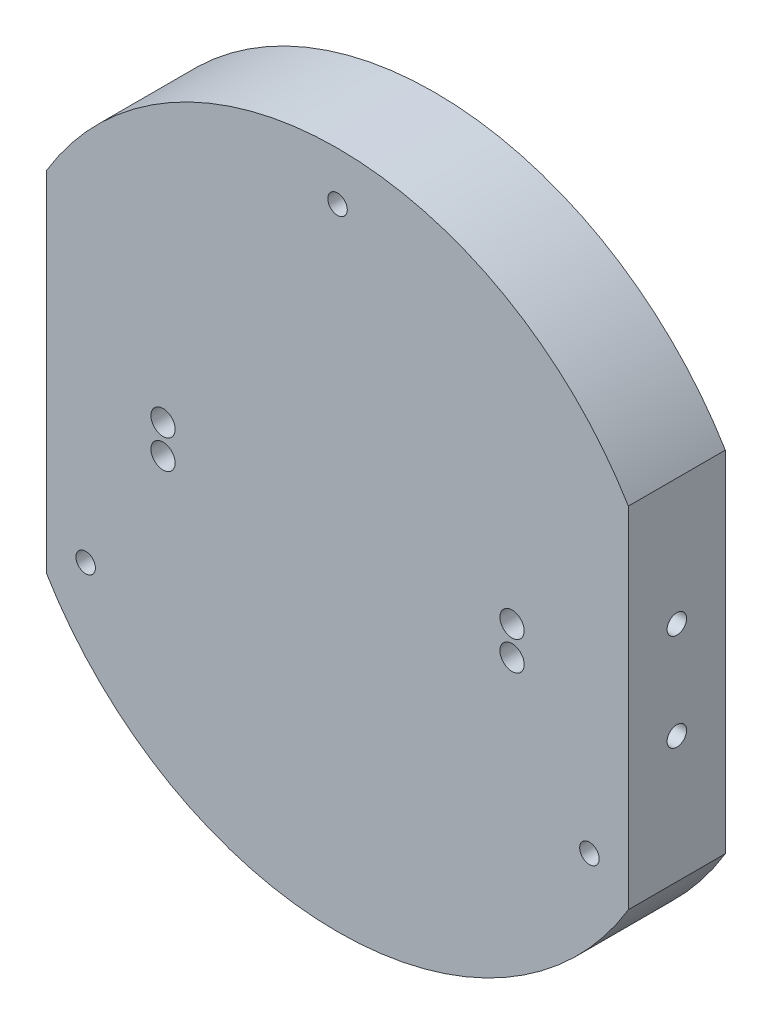
from build123d import *

# Parameters (mm, degrees)
SKETCH1_W                   = 177.8
SKETCH1_H                   = 177.8
EXTRUDE1_DEPTH              = 12.7
F_10_CLEARANCE_HOLE1_D      = 5.1054
CIRPATTERN1_COUNT           = 3
SKETCH5_W                   = 177.8
SKETCH5_H                   = 31.75
EXTRUDE2_DEPTH              = 1.5875
SKETCH8_R                   = 152.4
SKETCH8_R_2                 = 88.9
EXTRUDE3_DEPTH              = 13.7
SKETCH9_W                   = 254
SKETCH9_H                   = 254
SKETCH9_W_2                 = 152.4
SKETCH9_H_2                 = 177.8
EXTRUDE4_DEPTH              = 13.7
SKETCH10_W                  = 152.4
SKETCH10_H                  = 38.1
EXTRUDE5_DEPTH              = 12.7
EXTRUDE5_DEPTH_BACK         = 2.54
F_1_4_0_25_DIAMETER_HOLE1_D = 6.35
LPATTERN1_COUNT             = 2
LPATTERN1_PITCH             = 7.62
LPATTERN1_COUNT_DIR2        = 2
LPATTERN1_PITCH_DIR2        = 91.44
F_1_4_20_TAPPED_HOLE1_D     = 5.1054
F_1_4_20_TAPPED_HOLE1_DEPTH = 19.05
F_1_4_20_TAPPED_HOLE1_TIP   = 1.533817
F_1_4_20_TAPPED_HOLE2_D     = 5.1054
F_1_4_20_TAPPED_HOLE2_DEPTH = 19.05
F_1_4_20_TAPPED_HOLE2_TIP   = 1.533817
SKETCH17_R                  = 2.5527
EXTRUDE6_DEPTH              = 12.7


with BuildPart() as part:
    # Sketch1 → Extrude1 (new body)
    with BuildSketch(Plane.XY):
        Rectangle(SKETCH1_W, SKETCH1_H)
    extrude(amount=EXTRUDE1_DEPTH)

    # 10 Clearance Hole1 (through all)
    with Locations(Plane(origin=(0, 0, 0), x_dir=(-1, 0, 0), z_dir=(0, 0, -1))):
        with Locations((0, 76.2)):
            f_10_clearance_hole1 = Hole(F_10_CLEARANCE_HOLE1_D / 2)

    # CirPattern1: 10 Clearance Hole1 ×3 about axis
    cirpattern1_axis = Axis((0, 0, 0), (0, 0, 1))
    for i in range(1, CIRPATTERN1_COUNT):
        add(f_10_clearance_hole1.rotate(cirpattern1_axis, i * 360 / CIRPATTERN1_COUNT), mode=Mode.SUBTRACT)

    # Sketch5 → Extrude2 (cut)
    with BuildSketch(Plane.XY):
        Rectangle(SKETCH5_W, SKETCH5_H)
    extrude(amount=EXTRUDE2_DEPTH, mode=Mode.SUBTRACT)

    # Sketch8 → Extrude3 (cut, through all)
    with BuildSketch(Plane.XY.offset(12.7)):
        Circle(SKETCH8_R)
        Circle(SKETCH8_R_2, mode=Mode.SUBTRACT)
    extrude(amount=-EXTRUDE3_DEPTH, mode=Mode.SUBTRACT)

    # Sketch9 → Extrude4 (cut, through all)
    with BuildSketch(Plane.XY.offset(12.7)):
        Rectangle(SKETCH9_W, SKETCH9_H)
        Rectangle(SKETCH9_W_2, SKETCH9_H_2, mode=Mode.SUBTRACT)
    extrude(amount=-EXTRUDE4_DEPTH, mode=Mode.SUBTRACT)

    # Sketch10 → Extrude5 (add, two sides)
    with BuildSketch(Plane(origin=(0, 0, 0), x_dir=(-1, 0, 0), z_dir=(0, 0, -1))) as extrude5_sk:
        Rectangle(SKETCH10_W, SKETCH10_H)
    extrude(amount=EXTRUDE5_DEPTH)
    extrude(extrude5_sk.sketch, amount=-EXTRUDE5_DEPTH_BACK)

    # 1_4 _0.25_ Diameter Hole1 (through all)
    with Locations(Plane.XY.offset(12.7)):
        with Locations((-45.72, 3.81)):
            f_1_4_0_25_diameter_hole1 = Hole(F_1_4_0_25_DIAMETER_HOLE1_D / 2)

    # LPattern1: 1_4 _0.25_ Diameter Hole1 2 × 2
    with Locations(*[(j * LPATTERN1_PITCH_DIR2, -i * LPATTERN1_PITCH, 0) for i in range(LPATTERN1_COUNT) for j in range(LPATTERN1_COUNT_DIR2) if (i, j) != (0, 0)]):
        add(f_1_4_0_25_diameter_hole1, mode=Mode.SUBTRACT)

    # 1_4-20 Tapped Hole1
    with Locations(Plane.ZY.offset(76.2)):
        with Locations((0, 12.7), (0, -12.7)):
            Hole(F_1_4_20_TAPPED_HOLE1_D / 2, depth=F_1_4_20_TAPPED_HOLE1_DEPTH)
            with Locations((0, 0, -(F_1_4_20_TAPPED_HOLE1_DEPTH + F_1_4_20_TAPPED_HOLE1_TIP / 2))):  # 118° drill point
                Cone(0, F_1_4_20_TAPPED_HOLE1_D / 2, F_1_4_20_TAPPED_HOLE1_TIP, mode=Mode.SUBTRACT)

    # 1_4-20 Tapped Hole2
    with Locations(Plane(origin=(76.2, 0, 0), x_dir=(0, 0, -1), z_dir=(1, 0, 0))):
        with Locations((0, 12.7), (0, -12.7)):
            Hole(F_1_4_20_TAPPED_HOLE2_D / 2, depth=F_1_4_20_TAPPED_HOLE2_DEPTH)
            with Locations((0, 0, -(F_1_4_20_TAPPED_HOLE2_DEPTH + F_1_4_20_TAPPED_HOLE2_TIP / 2))):  # 118° drill point
                Cone(0, F_1_4_20_TAPPED_HOLE2_D / 2, F_1_4_20_TAPPED_HOLE2_TIP, mode=Mode.SUBTRACT)

    # Sketch17 → Extrude6 (add)
    with BuildSketch(Plane(origin=(0, 0, 0), x_dir=(-1, 0, 0), z_dir=(0, 0, -1))):
        with BuildLine():
            Line((76.2, -45.790501), (76.2, -19.05))
            Line((76.2, -19.05), (-76.2, -19.05))
            Line((-76.2, -19.05), (-76.2, -45.790501))
            ThreePointArc((-76.2, -45.790501), (0, -88.9), (76.2, -45.790501))
        make_face()
        with Locations((-65.991136, -38.1)):
            Circle(SKETCH17_R, mode=Mode.SUBTRACT)
        with Locations((65.991136, -38.1)):
            Circle(SKETCH17_R, mode=Mode.SUBTRACT)
        with BuildLine():
            Line((-76.2, 45.790501), (-76.2, 19.05))
            Line((-76.2, 19.05), (76.2, 19.05))
            Line((76.2, 19.05), (76.2, 45.790501))
            ThreePointArc((76.2, 45.790501), (0, 88.9), (-76.2, 45.790501))
        make_face()
        with Locations((0, 76.2)):
            Circle(SKETCH17_R, mode=Mode.SUBTRACT)
    extrude(amount=EXTRUDE6_DEPTH)


solid = part.part
